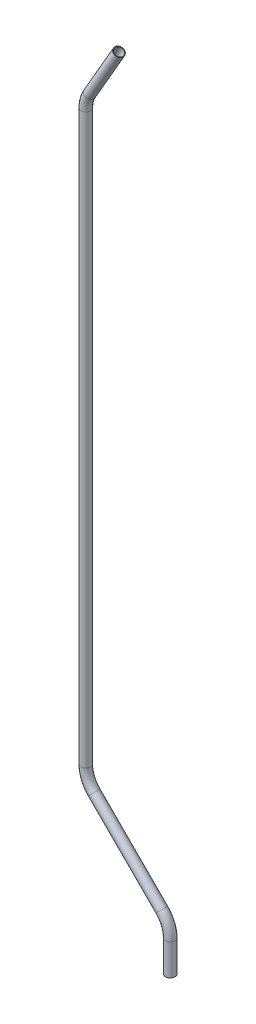
from build123d import *

# Parameters (mm, degrees)
SKETCH2_R   = 6.35
SKETCH2_R_2 = 5.5372


with BuildPart() as part:
    # Sweep1: sweep along a path in Sketch1
    with BuildLine(Plane.XY) as sweep1_path:
        Line((0, -253.63805), (0, -212.269586726))
        ThreePointArc((0, -212.269586726), (-2.900189811, -197.689347953), (-11.159231637, -185.328818363))
        Line((-11.159231637, -185.328818363), (-100.600768363, -95.887281637))
        ThreePointArc((-100.600768363, -95.887281637), (-108.859810189, -83.526752047), (-111.76, -68.946513274))
        Line((-111.76, -68.946513274), (-111.76, 682.844622495))
        ThreePointArc((-111.76, 682.844622495), (-110.461773982, 692.705628113), (-106.655567884, 701.894622495))
        Line((-106.655567884, 701.894622495), (-67.765909488, 769.253486726))
    # Sketch2 → Sweep1 (sweep)
    with BuildSketch(Plane(origin=(0, 0, 0), x_dir=(1, 0, 0), z_dir=(0, 1, 0))):
        with Locations((-111.76, 0)):
            Circle(SKETCH2_R)
        with Locations((-111.76, 0)):
            Circle(SKETCH2_R_2, mode=Mode.SUBTRACT)
    sweep(path=sweep1_path.line)


solid = part.part
